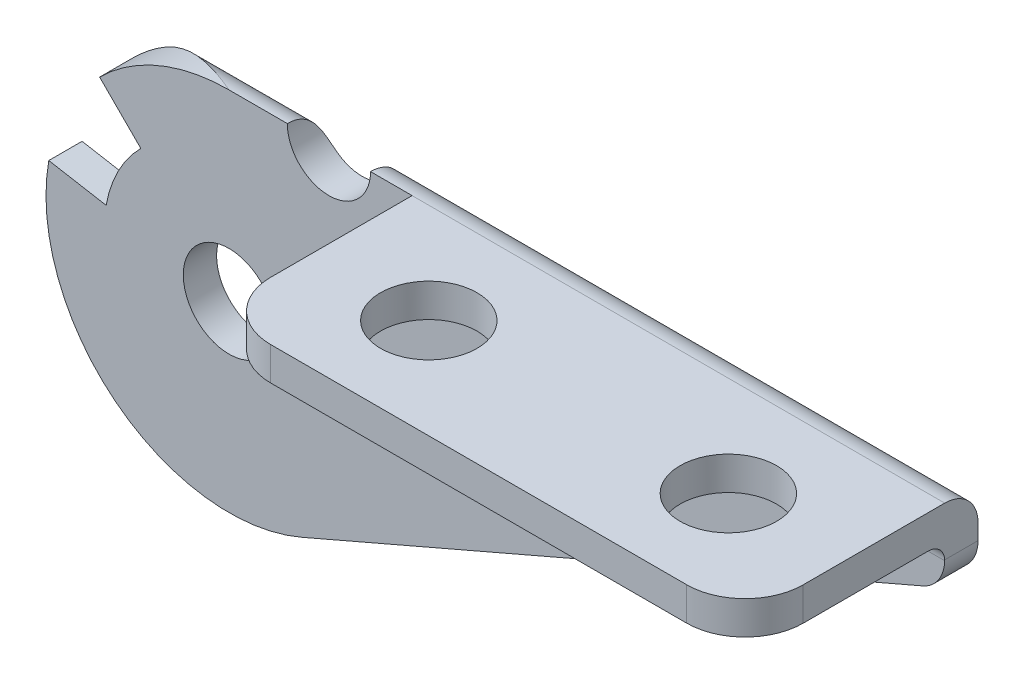
from build123d import *

# Parameters (mm, degrees)
SKETCH1_R               = 2.75
BOSS_EXTRUDE1_DEPTH     = 14
SKETCH2_W               = 24
SKETCH2_H               = 32
CUT_EXTRUDE1_DEPTH      = 65
CUT_EXTRUDE1_DEPTH_BACK = 65
SKETCH3_W               = 64
SKETCH3_H               = 24
CUT_EXTRUDE2_DEPTH      = 22
SKETCH4_R               = 2.9
CUT_EXTRUDE3_DEPTH      = 2
CUT_EXTRUDE3_DEPTH_BACK = 2
SKETCH5_R               = 2.9
CUT_EXTRUDE4_DEPTH      = 2
CUT_EXTRUDE4_DEPTH_BACK = 2
SKETCH6_R               = 2.5
CUT_EXTRUDE5_DEPTH      = 14


with BuildPart() as part:
    # Sketch1 → Boss-Extrude1 (new body)
    with BuildSketch(Plane.XY):
        with BuildLine():
            Line((4.363786096, 0.902605737), (41.672757219, 17.026406116))
            ThreePointArc((41.672757219, 17.026406116), (42.63848659, 17.837594003), (43, 19.045884969))
            Line((43, 19.045884969), (43, 22))
            Line((43, 22), (0, 22))
            ThreePointArc((0, 22), (-4.209517756, 21.162674858), (-7.778174593, 18.778174593))
            Line((-7.778174593, 18.778174593), (-5.303300859, 16.303300859))
            ThreePointArc((-5.303300859, 16.303300859), (-6.652581249, 14.463114599), (-7.386058148, 12.302361333))
            Line((-7.386058148, 12.302361333), (-10.832885283, 12.910129954))
            ThreePointArc((-10.832885283, 12.910129954), (-6.819638592, 2.369094516), (4.363786096, 0.902605737))
        make_face()
        with Locations((0, 11)):
            Circle(SKETCH1_R, mode=Mode.SUBTRACT)
    extrude(amount=BOSS_EXTRUDE1_DEPTH)

    # Sketch2 → Cut-Extrude1 (cut, two sides)
    with BuildSketch(Plane(origin=(0, 0, 0), x_dir=(0, 0, -1), z_dir=(1, 0, 0))) as cut_extrude1_sk:
        with Locations((-7, 11)):
            Rectangle(SKETCH2_W, SKETCH2_H)
        with BuildLine():
            Line((-14, 20), (-3, 20))
            ThreePointArc((-3, 20), (-2.292893219, 19.707106781), (-2, 19))
            Line((-2, 19), (-2, 0))
            Line((-2, 0), (0, 0))
            Line((0, 0), (0, 20))
            ThreePointArc((0, 20), (-0.585786438, 21.414213562), (-2, 22))
            Line((-2, 22), (-14, 22))
            Line((-14, 22), (-14, 20))
        make_face(mode=Mode.SUBTRACT)
    extrude(amount=CUT_EXTRUDE1_DEPTH, mode=Mode.SUBTRACT)
    extrude(cut_extrude1_sk.sketch, amount=-CUT_EXTRUDE1_DEPTH_BACK, mode=Mode.SUBTRACT)

    # Sketch3 → Cut-Extrude2 (cut)
    with BuildSketch(Plane(origin=(0, 0, 0), x_dir=(-1, 0, 0), z_dir=(0, 1, 0))):
        with Locations((-16, 7)):
            Rectangle(SKETCH3_W, SKETCH3_H)
        with BuildLine():
            Line((11, 0), (11, 2))
            Line((11, 2), (-11, 2))
            Line((-11, 2), (-11, 10.5))
            ThreePointArc((-11, 10.5), (-12.025126266, 12.974873734), (-14.5, 14))
            Line((-14.5, 14), (-39.5, 14))
            ThreePointArc((-39.5, 14), (-41.974873734, 12.974873734), (-43, 10.5))
            Line((-43, 10.5), (-43, 0))
            Line((-43, 0), (11, 0))
        make_face(mode=Mode.SUBTRACT)
    extrude(amount=CUT_EXTRUDE2_DEPTH, mode=Mode.SUBTRACT)

    # Sketch4 → Cut-Extrude3 (cut, two sides)
    with BuildSketch(Plane(origin=(0, 22, 0), x_dir=(-1, 0, 0), z_dir=(0, 1, 0))) as cut_extrude3_sk:
        with Locations((-18, 8)):
            Circle(SKETCH4_R)
    extrude(amount=CUT_EXTRUDE3_DEPTH, mode=Mode.SUBTRACT)
    extrude(cut_extrude3_sk.sketch, amount=-CUT_EXTRUDE3_DEPTH_BACK, mode=Mode.SUBTRACT)

    # Sketch5 → Cut-Extrude4 (cut, two sides)
    with BuildSketch(Plane(origin=(0, 22, 0), x_dir=(-1, 0, 0), z_dir=(0, 1, 0))) as cut_extrude4_sk:
        with Locations((-36, 8)):
            Circle(SKETCH5_R)
    extrude(amount=CUT_EXTRUDE4_DEPTH, mode=Mode.SUBTRACT)
    extrude(cut_extrude4_sk.sketch, amount=-CUT_EXTRUDE4_DEPTH_BACK, mode=Mode.SUBTRACT)

    # Sketch6 → Cut-Extrude5 (cut)
    with BuildSketch(Plane.XY):
        with Locations((6, 22)):
            Circle(SKETCH6_R)
    extrude(amount=CUT_EXTRUDE5_DEPTH, mode=Mode.SUBTRACT)


solid = part.part
